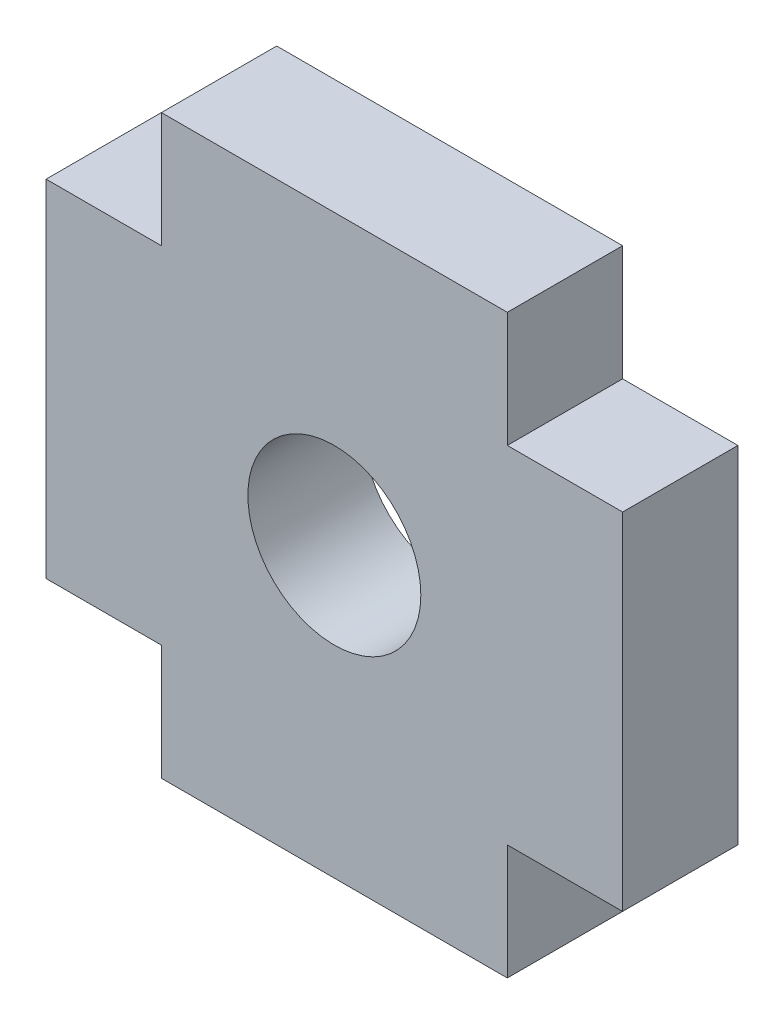
from build123d import *

# Parameters (mm, degrees)
MODEL_R             = 1.5
BOSS_EXTRUDE1_DEPTH = 2


with BuildPart() as part:
    # Model → Boss-Extrude1 (new body)
    with BuildSketch(Plane.XY):
        Polygon((-5, -3), (-3, -3), (-3, -5), (3, -5), (3, -3), (5, -3), (5, 3), (3, 3), (3, 5), (-3, 5), (-3, 3), (-5, 3), align=None)
        Circle(MODEL_R, mode=Mode.SUBTRACT)
    extrude(amount=BOSS_EXTRUDE1_DEPTH)


solid = part.part
